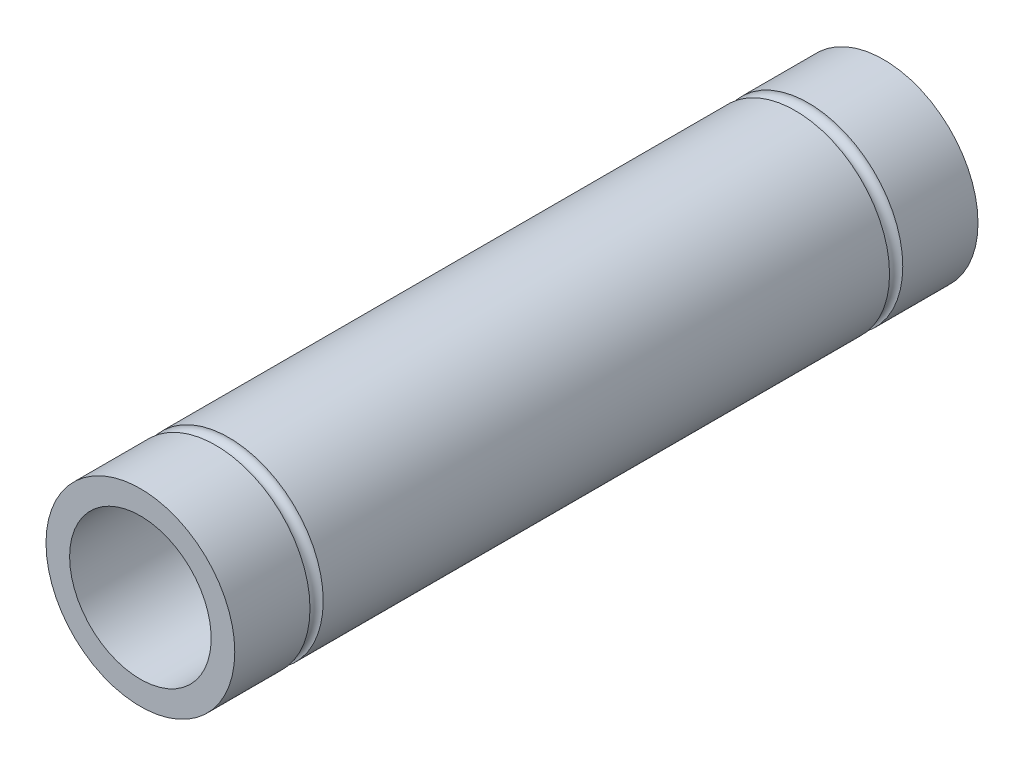
from build123d import *

# Parameters (mm, degrees)
BOSS_EXTRUDE1_DEPTH        = 50
F_3_8_0_3750_DOWEL_HOLE1_D = 9.525


with BuildPart() as part:
    # Sketch1 → Boss-Extrude1 (new body)
    with BuildSketch(Plane.XY):
        with BuildLine():
            Line((6.148361062, 1.5875), (3.862361062, 1.5875))
            Line((3.862361062, 1.5875), (3.862361062, -1.5875))
            Line((3.862361062, -1.5875), (6.148361062, -1.5875))
            ThreePointArc((6.148361062, -1.5875), (-6.35, 0), (6.148361062, 1.5875))
        make_face()
        with BuildLine():
            ThreePointArc((6.148361062, 1.5875), (6.35, 0), (6.148361062, -1.5875))
            Line((6.148361062, -1.5875), (3.862361062, -1.5875))
            Line((3.862361062, -1.5875), (3.862361062, 1.5875))
            Line((3.862361062, 1.5875), (6.148361062, 1.5875))
        make_face()
    extrude(amount=BOSS_EXTRUDE1_DEPTH)

    # 3/8 (0.3750) Dowel Hole1 (through all)
    with Locations(Plane(origin=(0, 0, 0), x_dir=(1, 0, 0), z_dir=(0, 0, -1))):
        with Locations((0, 0)):
            Hole(F_3_8_0_3750_DOWEL_HOLE1_D / 2)

    # Sketch5 → Cut-Revolve1 (revolve, cut)
    with BuildSketch(Plane(origin=(0, 0, 0), x_dir=(1, 0, 0), z_dir=(0, 1, 0))):
        with BuildLine():
            ThreePointArc((-6.35, -44.05), (-5.9055, -44.4945), (-6.35, -44.939))
            Line((-6.35, -44.939), (-6.35, -44.05))
        make_face()
        with BuildLine():
            Line((-6.35, -5.95), (-6.35, -5.061))
            ThreePointArc((-6.35, -5.061), (-5.9055, -5.5055), (-6.35, -5.95))
        make_face()
    revolve(axis=Axis((0, 0, 50), (0, 0, -1)), mode=Mode.SUBTRACT)


solid = part.part
